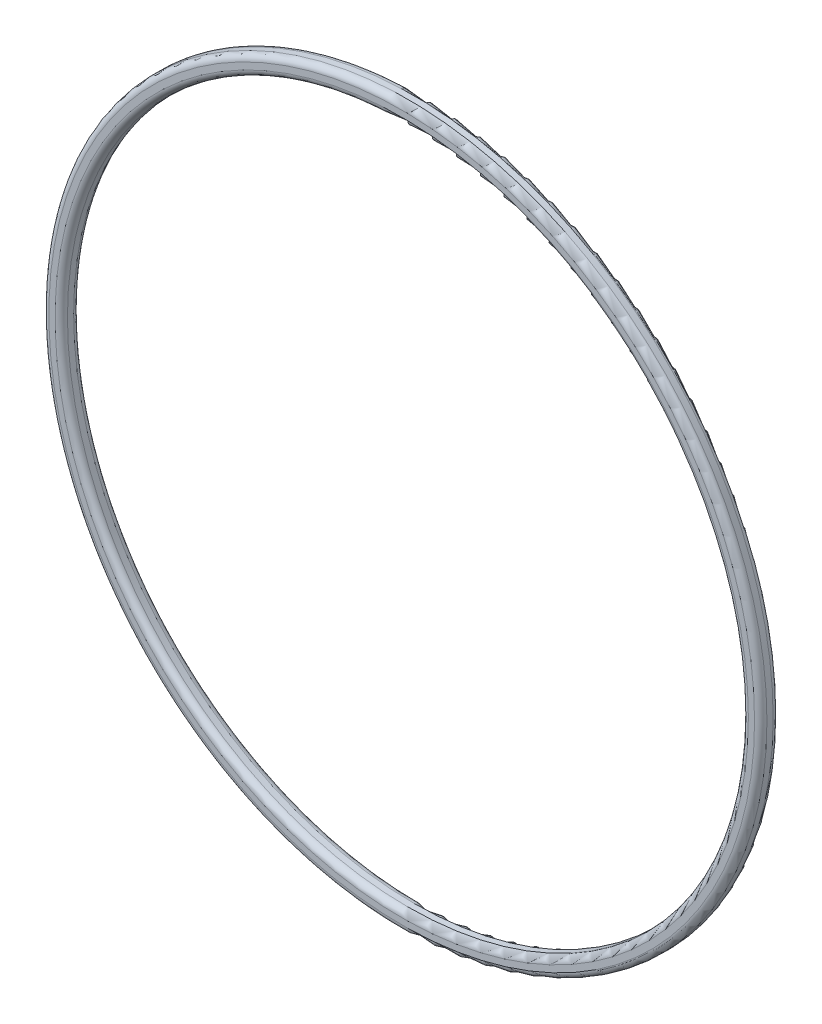
from build123d import *

# Parameters (mm, degrees)
SCHIZZO1_R                   = 58
SCHIZZO1_R_2                 = 55
ESTRUSIONE_ESTRUSIONE1_DEPTH = 3
RACCORDO1_R                  = 1


with BuildPart() as part:
    # Schizzo1 → Estrusione-Estrusione1 (new body)
    with BuildSketch(Plane.XY):
        Circle(SCHIZZO1_R)
        Circle(SCHIZZO1_R_2, mode=Mode.SUBTRACT)
    extrude(amount=ESTRUSIONE_ESTRUSIONE1_DEPTH)

    # Raccordo1
    raccordo1_edges = [part.edges().sort_by_distance(p)[0] for p in [
        (-58, 0, 0),
        (-58, 0, 3),
        (-55, 0, 0),
        (-55, 0, 3),
    ]]
    fillet(raccordo1_edges, radius=RACCORDO1_R)


solid = part.part
